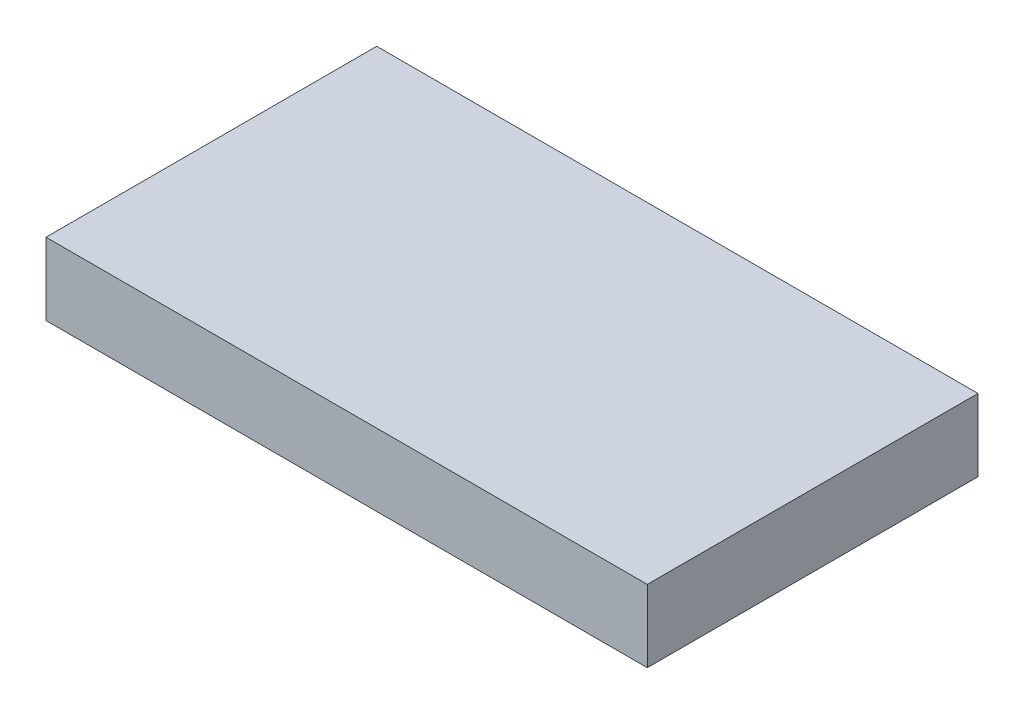
from build123d import *

# Parameters (mm, degrees)
ESQUISSE1_W        = 100
ESQUISSE1_H        = 55
BOSS_EXTRU_1_DEPTH = 12


with BuildPart() as part:
    # Esquisse1 → Boss.-Extru.1 (new body)
    with BuildSketch(Plane(origin=(0, 0, 0), x_dir=(1, 0, 0), z_dir=(0, 1, 0))):
        with Locations((50, 27.5)):
            Rectangle(ESQUISSE1_W, ESQUISSE1_H)
    extrude(amount=BOSS_EXTRU_1_DEPTH)


solid = part.part
